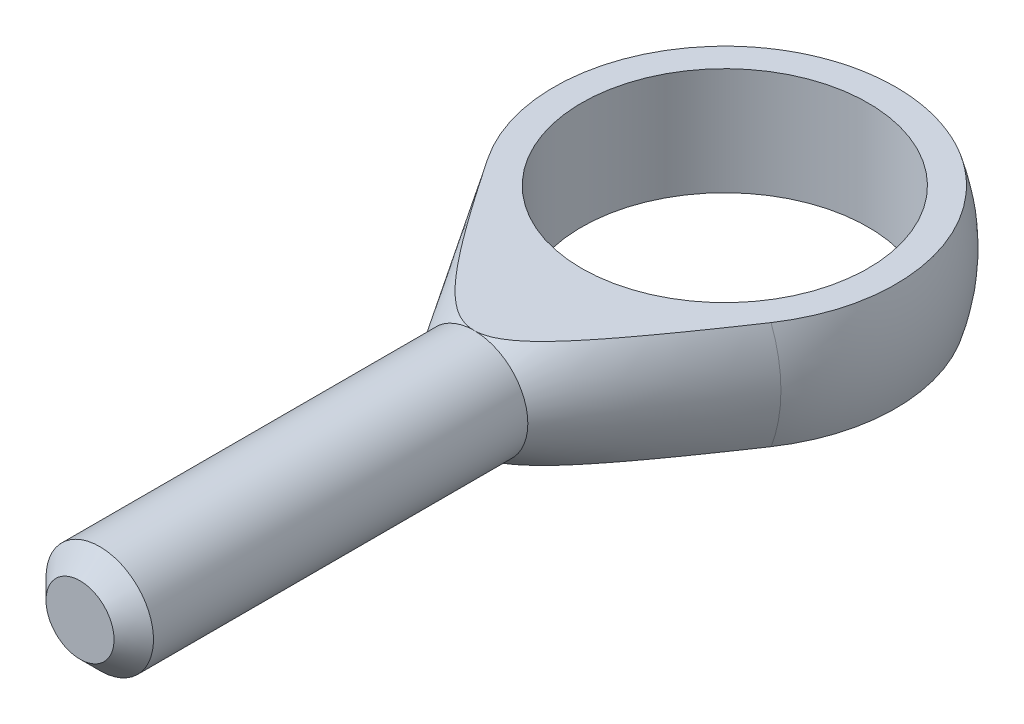
from build123d import *

# Parameters (mm, degrees)
SZKIC1_W                        = 3
SZKIC1_H                        = 22
WYTNIJ_WYCI_GNI_CIE1_DEPTH      = 11
WYTNIJ_WYCI_GNI_CIE1_DEPTH_BACK = 11
SZKIC3_R                        = 8
WYTNIJ_WYCI_GNI_CIE2_DEPTH      = 4
WYTNIJ_WYCI_GNI_CIE2_DEPTH_BACK = 4
SFAZOWANIE1_SIZE                = 1.1


with BuildPart() as part:
    # Szkic1 → Obrót1 (revolve)
    with BuildSketch(Plane(origin=(0, 0, 0), x_dir=(1, 0, 0), z_dir=(0, 1, 0))):
        with BuildLine():
            Line((0, 10), (0, -14))
            Line((0, -14), (3, -14))
            Line((3, -14), (8.46133223, -5.329714522))
            ThreePointArc((8.46133223, -5.329714522), (8.754917053, 4.832331465), (0, 10))
        make_face()
        with Locations((1.5, -25)):
            Rectangle(SZKIC1_W, SZKIC1_H)
    revolve(axis=Axis((0, 0, -26.043516498), (0, 0, 1)))

    # Szkic2 → Wytnij-wyciągnięcie1 (cut, two sides)
    with BuildSketch(Plane(origin=(0, 0, 0), x_dir=(0, 0, -1), z_dir=(1, 0, 0))) as wytnij_wyci_gni_cie1_sk:
        with BuildLine():
            Line((-14, 3), (9.539392014, 3))
            ThreePointArc((9.539392014, 3), (3.447736008, 9.386858709), (-5.329714522, 8.46133223))
            Line((-5.329714522, 8.46133223), (-14, 3))
        make_face()
        with BuildLine():
            Line((-14, -3), (9.539392014, -3))
            ThreePointArc((9.539392014, -3), (3.447736008, -9.386858709), (-5.329714522, -8.46133223))
            Line((-5.329714522, -8.46133223), (-14, -3))
        make_face()
    extrude(amount=WYTNIJ_WYCI_GNI_CIE1_DEPTH, mode=Mode.SUBTRACT)
    extrude(wytnij_wyci_gni_cie1_sk.sketch, amount=-WYTNIJ_WYCI_GNI_CIE1_DEPTH_BACK, mode=Mode.SUBTRACT)

    # Szkic3 → Wytnij-wyciągnięcie2 (cut, two sides)
    with BuildSketch(Plane(origin=(0, 0, 0), x_dir=(1, 0, 0), z_dir=(0, 1, 0))) as wytnij_wyci_gni_cie2_sk:
        Circle(SZKIC3_R)
    extrude(amount=WYTNIJ_WYCI_GNI_CIE2_DEPTH, mode=Mode.SUBTRACT)
    extrude(wytnij_wyci_gni_cie2_sk.sketch, amount=-WYTNIJ_WYCI_GNI_CIE2_DEPTH_BACK, mode=Mode.SUBTRACT)

    # Sfazowanie1
    sfazowanie1_edges = [part.edges().sort_by_distance(p)[0] for p in [
        (-3, 0, 36),
    ]]
    chamfer(sfazowanie1_edges, length=SFAZOWANIE1_SIZE)


solid = part.part
